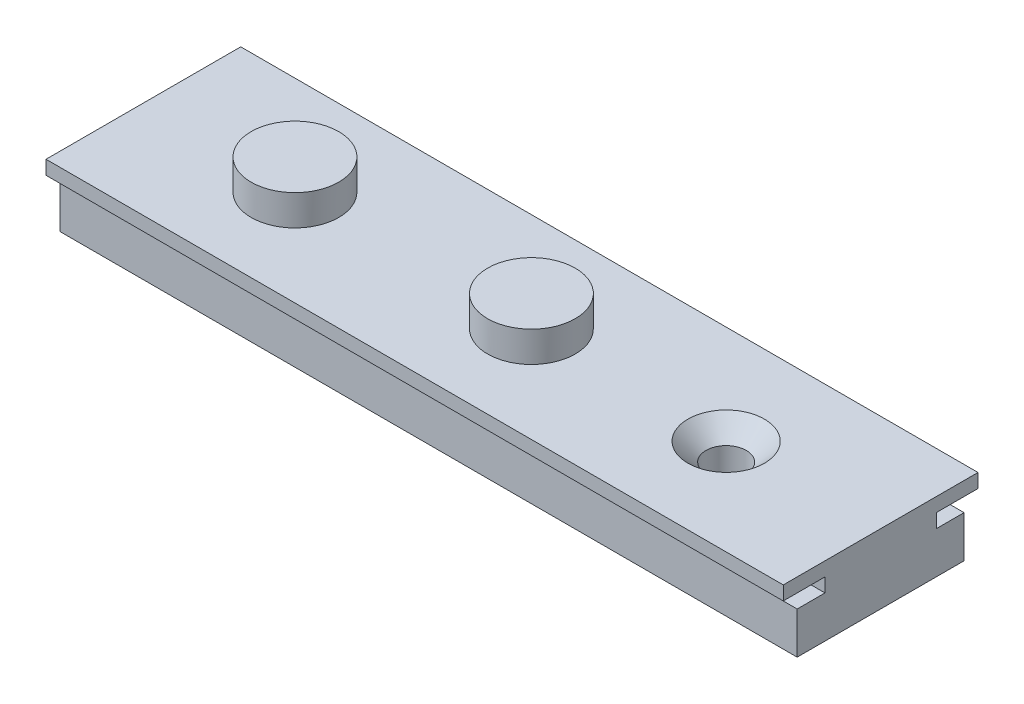
from build123d import *

# Parameters (mm, degrees)
BOSS_EXTRUDE1_DEPTH                                  = 53
CSK_FOR_M2_5_COUNTERSUNK_FLAT_HEAD_SCREW_D           = 2.9
CSK_FOR_M2_5_COUNTERSUNK_FLAT_HEAD_SCREW_DEPTH       = 14
CSK_FOR_M2_5_COUNTERSUNK_FLAT_HEAD_SCREW_CSINK_D     = 5.5
CSK_FOR_M2_5_COUNTERSUNK_FLAT_HEAD_SCREW_CSINK_ANGLE = 90
CSK_FOR_M2_5_COUNTERSUNK_FLAT_HEAD_SCREW_TIP         = 0.871247898
BOSS_EXTRUDE2_DEPTH                                  = 2.2


with BuildPart() as part:
    # Sketch1 → Boss-Extrude1 (new body)
    with BuildSketch(Plane(origin=(0, 0, 0), x_dir=(0, 0, -1), z_dir=(1, 0, 0))):
        Polygon((4, 0.5), (6, 0.5), (6, -2.5), (-6, -2.5), (-6, 0.5), (-4, 0.5), (-4, 1.5), (-7, 1.5), (-7, 2.5), (7, 2.5), (7, 1.5), (4, 1.5), align=None)
    extrude(amount=BOSS_EXTRUDE1_DEPTH)

    # CSK for M2.5 Countersunk Flat Head Screw1
    with Locations(Plane(origin=(42, 2.5, 0.10398467), x_dir=(0, 0, 1), z_dir=(0, 1, 0))):
        with Locations((0, 0)):
            CounterSinkHole(CSK_FOR_M2_5_COUNTERSUNK_FLAT_HEAD_SCREW_D / 2, CSK_FOR_M2_5_COUNTERSUNK_FLAT_HEAD_SCREW_CSINK_D / 2, depth=CSK_FOR_M2_5_COUNTERSUNK_FLAT_HEAD_SCREW_DEPTH, counter_sink_angle=CSK_FOR_M2_5_COUNTERSUNK_FLAT_HEAD_SCREW_CSINK_ANGLE)
            with Locations((0, 0, -(CSK_FOR_M2_5_COUNTERSUNK_FLAT_HEAD_SCREW_DEPTH + CSK_FOR_M2_5_COUNTERSUNK_FLAT_HEAD_SCREW_TIP / 2))):  # 118° drill point
                Cone(0, CSK_FOR_M2_5_COUNTERSUNK_FLAT_HEAD_SCREW_D / 2, CSK_FOR_M2_5_COUNTERSUNK_FLAT_HEAD_SCREW_TIP, mode=Mode.SUBTRACT)

    # Sketch2 → Boss-Extrude2 (add)
    with BuildSketch(Plane(origin=(0, 2.5, 0), x_dir=(1, 0, 0), z_dir=(0, 1, 0))):
        with BuildLine():
            ThreePointArc((14.15, -0.10398467), (11, 3.04601533), (7.85, -0.10398467))
            ThreePointArc((7.85, -0.10398467), (11, -3.25398467), (14.15, -0.10398467))
        make_face()
        with BuildLine():
            ThreePointArc((31.15, -0.10398467), (28, 3.04601533), (24.85, -0.10398467))
            ThreePointArc((24.85, -0.10398467), (28, -3.25398467), (31.15, -0.10398467))
        make_face()
    extrude(amount=BOSS_EXTRUDE2_DEPTH)


solid = part.part
